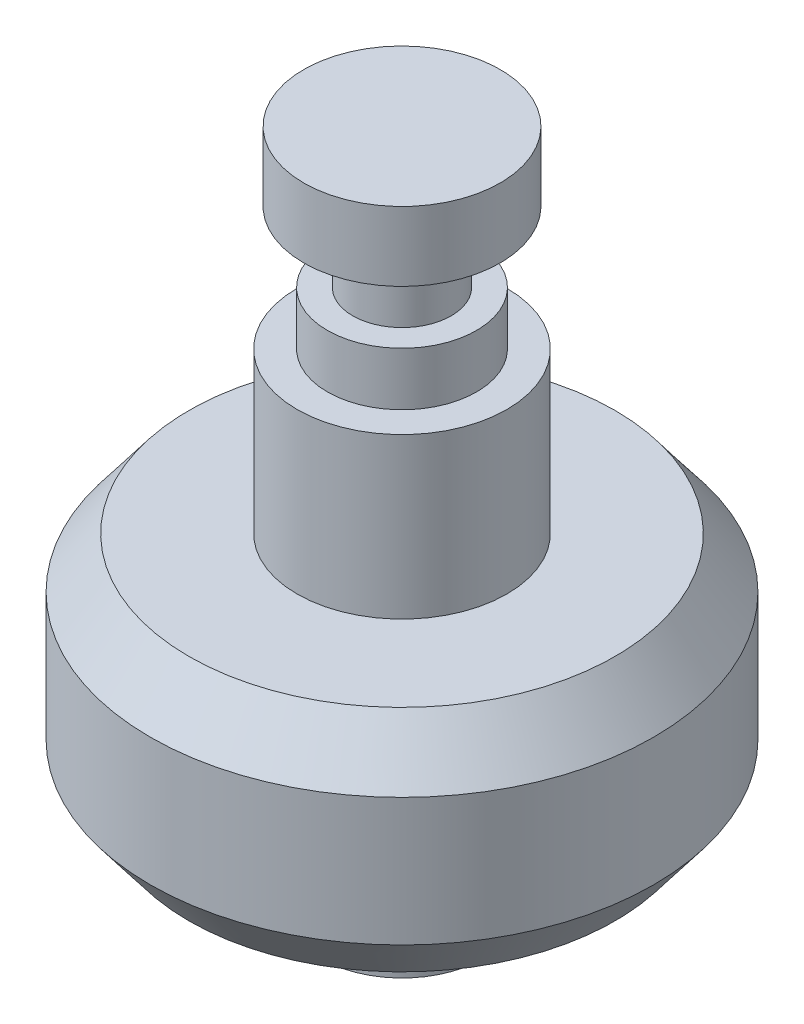
from build123d import *


with BuildPart() as part:
    # Sketch1 → Revolve1 (revolve)
    with BuildSketch(Plane(origin=(0, 0, 0), x_dir=(0, 0, -1), z_dir=(1, 0, 0))):
        Polygon((0, 0), (0, -32.4358), (3.8735, -32.4358), (3.8735, -27.7368), (10.16, -27.7368), (12.0015, -25.3238), (12.0015, -19.2278), (10.16, -16.8148), (5.0038, -16.8148), (5.0038, -9.1948), (3.556, -9.1948), (3.556, -6.6548), (2.3495, -6.6548), (2.3495, -3.302), (4.6863, -3.302), (4.6863, 0), align=None)
    revolve(axis=Axis((0, 0, 0), (0, -1, 0)))


solid = part.part
